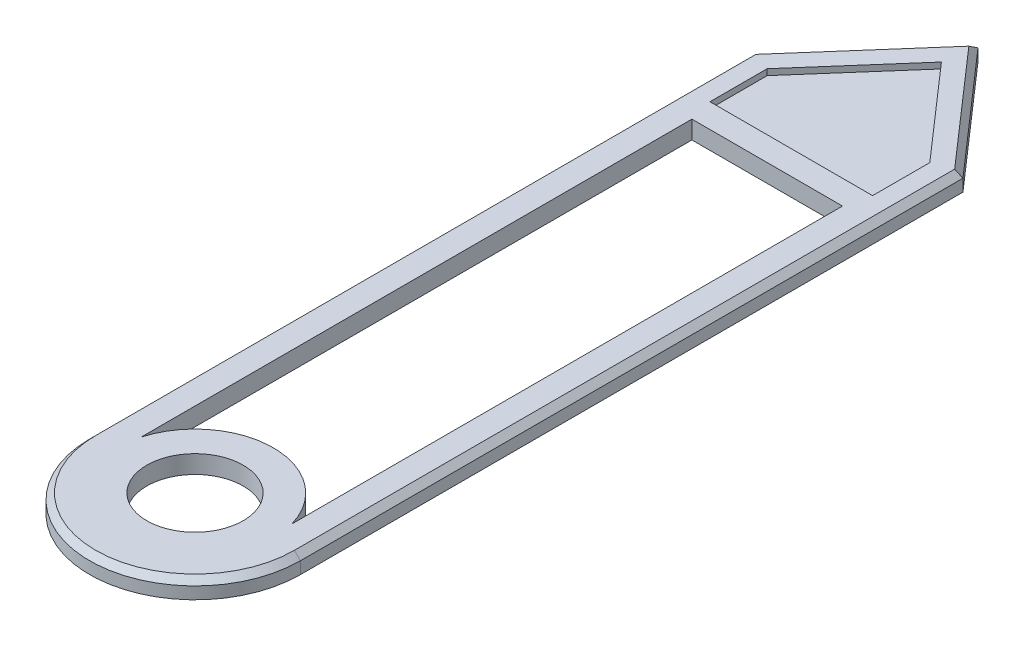
from build123d import *

# Parameters (mm, degrees)
SKETCH1_R           = 0.8
BOSS_EXTRUDE1_DEPTH = 0.3
CUT_EXTRUDE1_DEPTH  = 0.1
CHAMFER1_SIZE       = 0.1


with BuildPart() as part:
    # Sketch1 → Boss-Extrude1 (new body)
    with BuildSketch(Plane(origin=(0, 0, 0), x_dir=(1, 0, 0), z_dir=(0, 1, 0))):
        with BuildLine():
            Line((-1.75, 0), (-1.75, 11))
            Line((-1.75, 11), (0, 13))
            Line((0, 13), (1.75, 11))
            Line((1.75, 11), (1.75, 0))
            ThreePointArc((1.75, 0), (0, -1.75), (-1.75, 0))
        make_face()
        Circle(SKETCH1_R, mode=Mode.SUBTRACT)
        with BuildLine():
            Line((-1.25, 0.357071421), (-1.25, 9.5))
            Line((-1.25, 9.5), (1.25, 9.5))
            Line((1.25, 9.5), (1.25, 0.357071421))
            ThreePointArc((1.25, 0.357071421), (0, 1.3), (-1.25, 0.357071421))
        make_face(mode=Mode.SUBTRACT)
    extrude(amount=BOSS_EXTRUDE1_DEPTH)

    # Sketch2 → Cut-Extrude1 (cut)
    with BuildSketch(Plane(origin=(0, 0.3, 0), x_dir=(1, 0, 0), z_dir=(0, 1, 0))):
        Polygon((-1.35, 10.849705954), (-1.35, 9.9), (1.35, 9.9), (1.35, 10.849705954), (0, 12.392563096), align=None)
    extrude(amount=-CUT_EXTRUDE1_DEPTH, mode=Mode.SUBTRACT)

    # Chamfer1
    chamfer1_edges = [part.edges().sort_by_distance(p)[0] for p in [
        (0.875, 0.3, -12),
        (-0.875, 0.3, -12),
        (-1.75, 0.3, -5.5),
        (0, 0.3, 1.75),
        (1.75, 0.3, -5.5),
    ]]
    chamfer(chamfer1_edges, length=CHAMFER1_SIZE)


solid = part.part
